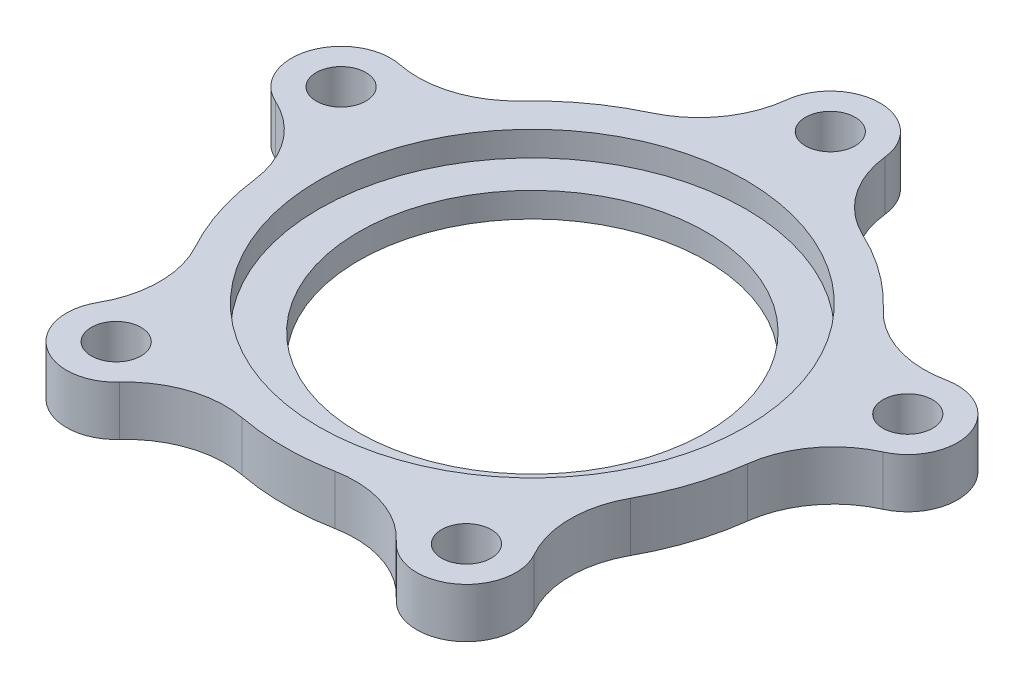
from build123d import *

# Parameters (mm, degrees)
SKETCH1_R           = 3.175
SKETCH1_R_2         = 27.305
BOSS_EXTRUDE4_DEPTH = 6.35
SKETCH1_6_R         = 27.305
SKETCH1_6_R_2       = 22.225
BOSS_EXTRUDE5_DEPTH = 3.175
FILLET2_R           = 12.7


with BuildPart() as part:
    # Sketch1 → Boss-Extrude4 (new body)
    with BuildSketch(Plane(origin=(0, 0, 0), x_dir=(1, 0, 0), z_dir=(0, 1, 0))):
        with BuildLine():
            Line((6.35, 31.108519733), (6.35, 38.1))
            ThreePointArc((6.35, 38.1), (0, 44.45), (-6.35, 38.1))
            Line((-6.35, 38.1), (-6.35, 31.108519733))
            ThreePointArc((-6.35, 31.108519733), (-18.66218176, 25.686289571), (-27.62370249, 15.652270146))
            Line((-27.62370249, 15.652270146), (-34.272995357, 17.812756364))
            ThreePointArc((-34.272995357, 17.812756364), (-42.274462149, 13.7358054), (-38.197511185, 5.734338607))
            Line((-38.197511185, 5.734338607), (-31.548218319, 3.573852389))
            ThreePointArc((-31.548218319, 3.573852389), (-30.196044392, -9.811289571), (-23.422387034, -21.434884782))
            Line((-23.422387034, -21.434884782), (-27.531876027, -27.091111134))
            ThreePointArc((-27.531876027, -27.091111134), (-26.127054464, -35.9608054), (-17.257360198, -34.555983838))
            Line((-17.257360198, -34.555983838), (-13.147871206, -28.899757486))
            ThreePointArc((-13.147871206, -28.899757486), (0, -31.75), (13.147871206, -28.899757486))
            Line((13.147871206, -28.899757486), (17.257360198, -34.555983838))
            ThreePointArc((17.257360198, -34.555983838), (26.127054464, -35.9608054), (27.531876027, -27.091111134))
            Line((27.531876027, -27.091111134), (23.422387034, -21.434884782))
            ThreePointArc((23.422387034, -21.434884782), (30.196044392, -9.811289571), (31.548218319, 3.573852389))
            Line((31.548218319, 3.573852389), (38.197511185, 5.734338607))
            ThreePointArc((38.197511185, 5.734338607), (42.274462149, 13.7358054), (34.272995357, 17.812756364))
            Line((34.272995357, 17.812756364), (27.62370249, 15.652270146))
            ThreePointArc((27.62370249, 15.652270146), (18.66218176, 25.686289571), (6.35, 31.108519733))
        make_face()
        with Locations((0, 38.1)):
            Circle(SKETCH1_R, mode=Mode.SUBTRACT)
        Circle(SKETCH1_R_2, mode=Mode.SUBTRACT)
        with Locations((36.235253271, 11.773547486)):
            Circle(SKETCH1_R, mode=Mode.SUBTRACT)
        with Locations((-36.235253271, 11.773547486)):
            Circle(SKETCH1_R, mode=Mode.SUBTRACT)
        with Locations((22.394618112, -30.823547486)):
            Circle(SKETCH1_R, mode=Mode.SUBTRACT)
        with Locations((-22.394618112, -30.823547486)):
            Circle(SKETCH1_R, mode=Mode.SUBTRACT)
    extrude(amount=BOSS_EXTRUDE4_DEPTH)

    # Sketch1_6 → Boss-Extrude5 (add)
    with BuildSketch(Plane(origin=(0, 0, 0), x_dir=(1, 0, 0), z_dir=(0, 1, 0))):
        Circle(SKETCH1_6_R)
        Circle(SKETCH1_6_R_2, mode=Mode.SUBTRACT)
    extrude(amount=BOSS_EXTRUDE5_DEPTH)

    # Fillet2
    fillet2_edges = [part.edges().sort_by_distance(p)[0] for p in [
        (27.62370249, 3.175, -15.652270146),
        (31.548218319, 3.175, -3.573852389),
        (23.422387034, 3.175, 21.434884782),
        (13.147871206, 3.175, 28.899757486),
        (-13.147871206, 3.175, 28.899757486),
        (-23.422387034, 3.175, 21.434884782),
        (-31.548218319, 3.175, -3.573852389),
        (-27.62370249, 3.175, -15.652270146),
        (-6.35, 3.175, -31.108519733),
        (6.35, 3.175, -31.108519733),
    ]]
    fillet(fillet2_edges, radius=FILLET2_R)


solid = part.part
